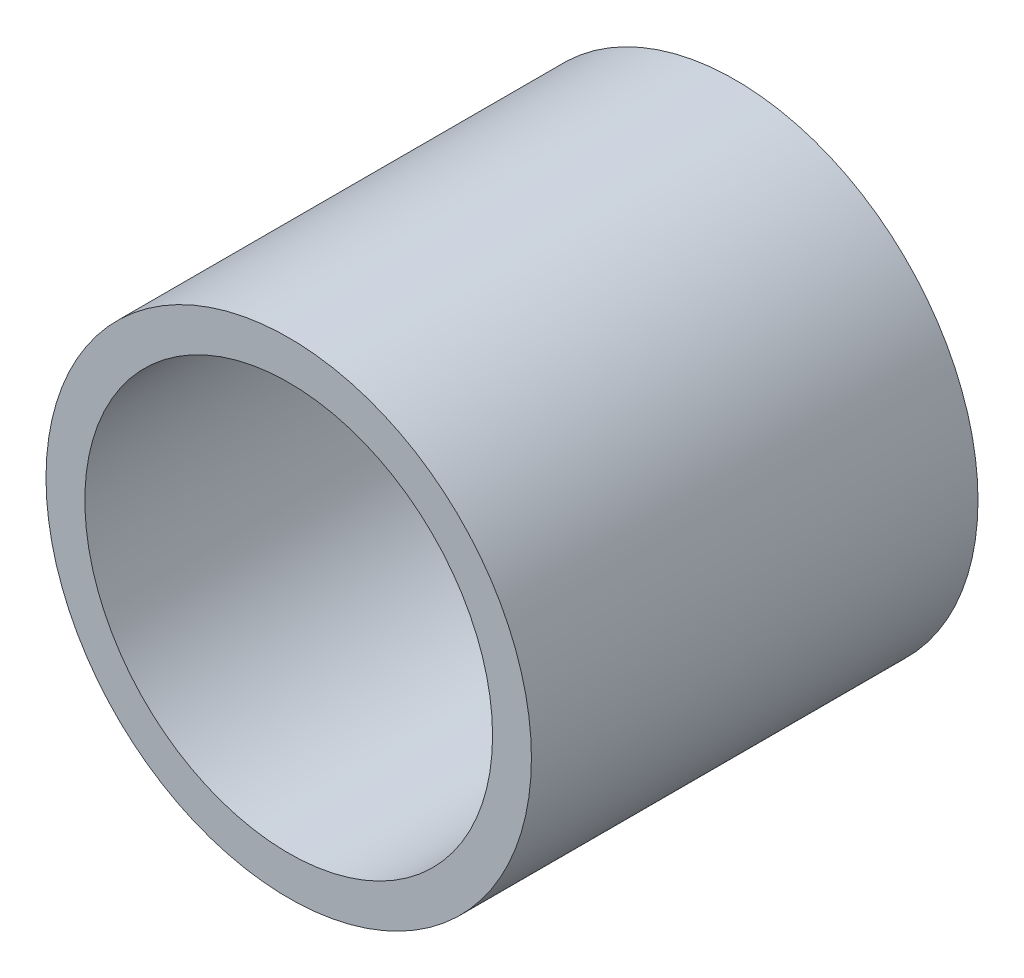
from build123d import *

# Parameters (mm, degrees)
SKETCH1_R           = 12.5
BOSS_EXTRUDE2_DEPTH = 23
SKETCH3_R           = 10.5
CUT_EXTRUDE1_DEPTH  = 20


with BuildPart() as part:
    # Sketch1 → Boss-Extrude2 (new body)
    with BuildSketch(Plane.XY):
        Circle(SKETCH1_R)
    extrude(amount=BOSS_EXTRUDE2_DEPTH)

    # Sketch3 → Cut-Extrude1 (cut)
    with BuildSketch(Plane.XY.offset(23)):
        Circle(SKETCH3_R)
    extrude(amount=-CUT_EXTRUDE1_DEPTH, mode=Mode.SUBTRACT)


solid = part.part
